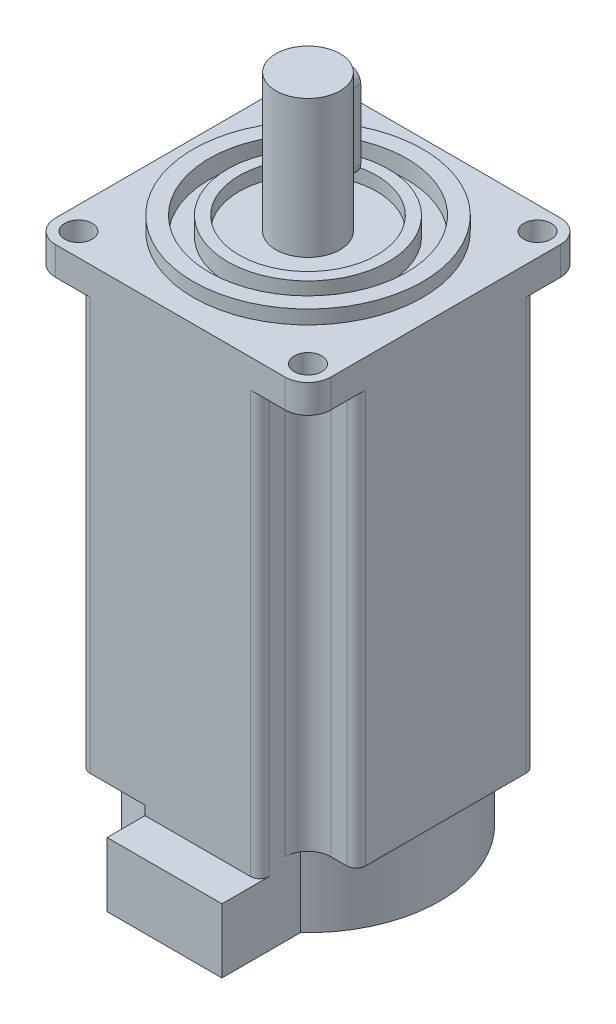
from build123d import *

# Parameters (mm, degrees)
SKETCH_2_W               = 60
SKETCH_2_H               = 60
EXTRUDE_1_DEPTH          = 96
SKETCH_3_W               = 10.5
SKETCH_3_H               = 10.5
CUT_EXTRUDE_1_DEPTH      = 97
PATTERN_CIRCULAR_1_COUNT = 4
SKETCH_4_W               = 60
SKETCH_4_H               = 60
EXTRUDE_2_DEPTH          = 6.2
SKETCH_5_R               = 25
EXTRUDE_3_DEPTH          = 3
SKETCH_8_R               = 21.5
SKETCH_8_R_2             = 17.5
CUT_EXTRUDE_3_DEPTH      = 4
SKETCH_9_R               = 15
CUT_EXTRUDE_4_DEPTH      = 3
SKETCH_10_R              = 7
EXTRUDE_5_DEPTH          = 30
FILLET_1_R               = 5
FILLET_2_R               = 2
FILLET_3_R               = 5
SKETCH_13_R              = 28.75
EXTRUDE_6_DEPTH          = 16
EXTRUDE_START            = 16
SKETCH_14_W              = 25
SKETCH_14_H              = 17.123890562
EXTRUDE_7_DEPTH          = 14
EXTRUDE_8_DEPTH          = 2
HOLE_WIZARD_6_0_6_1_D    = 6
CUT_EXTRUDE_5_DEPTH      = 3
EXTRUDE_9_DEPTH          = 5


with BuildPart() as part:
    # Sketch 2 → Extrude 1 (new body)
    with BuildSketch(Plane(origin=(0, 0, 0), x_dir=(1, 0, 0), z_dir=(0, 1, 0))):
        Rectangle(SKETCH_2_W, SKETCH_2_H)
    extrude(amount=-EXTRUDE_1_DEPTH)

    # Sketch 3 → Cut-Extrude 1 (cut, through all)
    with BuildSketch(Plane(origin=(0, 0, 0), x_dir=(1, 0, 0), z_dir=(0, 1, 0))):
        with Locations((-24.75, -24.75)):
            Rectangle(SKETCH_3_W, SKETCH_3_H)
    cut_extrude_1 = extrude(amount=-CUT_EXTRUDE_1_DEPTH, mode=Mode.SUBTRACT)

    # Pattern Circular 1: Cut-Extrude 1 ×4 about axis
    pattern_circular_1_axis = Axis((0, 0, 0), (0, 1, 0))
    for i in range(1, PATTERN_CIRCULAR_1_COUNT):
        add(cut_extrude_1.rotate(pattern_circular_1_axis, i * 360 / PATTERN_CIRCULAR_1_COUNT), mode=Mode.SUBTRACT)

    # Sketch 4 → Extrude 2 (add)
    with BuildSketch(Plane(origin=(0, 0, 0), x_dir=(1, 0, 0), z_dir=(0, 1, 0))):
        Rectangle(SKETCH_4_W, SKETCH_4_H)
    extrude(amount=-EXTRUDE_2_DEPTH)

    # Sketch 5 → Extrude 3 (add)
    with BuildSketch(Plane(origin=(0, 0, 0), x_dir=(1, 0, 0), z_dir=(0, 1, 0))):
        Circle(SKETCH_5_R)
    extrude(amount=EXTRUDE_3_DEPTH)

    # Sketch 8 → Cut-Extrude 3 (cut)
    with BuildSketch(Plane(origin=(0, 3, 0), x_dir=(1, 0, 0), z_dir=(0, 1, 0))):
        Circle(SKETCH_8_R)
        Circle(SKETCH_8_R_2, mode=Mode.SUBTRACT)
    extrude(amount=-CUT_EXTRUDE_3_DEPTH, mode=Mode.SUBTRACT)

    # Sketch 9 → Cut-Extrude 4 (cut)
    with BuildSketch(Plane(origin=(0, 3, 0), x_dir=(1, 0, 0), z_dir=(0, 1, 0))):
        Circle(SKETCH_9_R)
    extrude(amount=-CUT_EXTRUDE_4_DEPTH, mode=Mode.SUBTRACT)

    # Sketch 10 → Extrude 5 (add)
    with BuildSketch(Plane(origin=(0, 0, 0), x_dir=(1, 0, 0), z_dir=(0, 1, 0))):
        Circle(SKETCH_10_R)
    extrude(amount=EXTRUDE_5_DEPTH)

    # Fillet 1
    fillet_1_edges = [part.edges().sort_by_distance(p)[0] for p in [
        (-19.5, -51.1, 19.5),
        (-19.5, -51.1, -19.5),
        (19.5, -51.1, -19.5),
        (19.5, -51.1, 19.5),
    ]]
    fillet(fillet_1_edges, radius=FILLET_1_R)

    # Fillet 2
    fillet_2_edges = [part.edges().sort_by_distance(p)[0] for p in [
        (-30, -51.1, 19.5),
        (-19.5, -51.1, 30),
        (-19.5, -51.1, -30),
        (-30, -51.1, -19.5),
        (30, -51.1, -19.5),
        (19.5, -51.1, -30),
        (19.5, -51.1, 30),
        (30, -51.1, 19.5),
    ]]
    fillet(fillet_2_edges, radius=FILLET_2_R)

    # Fillet 3
    fillet_3_edges = [part.edges().sort_by_distance(p)[0] for p in [
        (30, -3.1, 30),
        (30, -3.1, -30),
        (-30, -3.1, -30),
        (-30, -3.1, 30),
    ]]
    fillet(fillet_3_edges, radius=FILLET_3_R)

    # Sketch 13 → Extrude 6 (add)
    with BuildSketch(Plane.XZ.offset(96)):
        Circle(SKETCH_13_R)
    extrude(amount=EXTRUDE_6_DEPTH)

    # Sketch 14 → Extrude 7 (add)
    with BuildSketch(Plane.XZ.offset(96).offset(EXTRUDE_START)):
        with Locations((7, 29.688054719)):
            Rectangle(SKETCH_14_W, SKETCH_14_H)
    extrude(amount=-EXTRUDE_7_DEPTH)

    # Sketch 15 → Extrude 8 (add)
    with BuildSketch(Plane(origin=(0, -98, 0), x_dir=(1, 0, 0), z_dir=(0, 1, 0))):
        with BuildLine():
            Line((-5.5, -30), (17.5, -30))
            ThreePointArc((17.5, -30), (18.914213562, -29.414213562), (19.5, -28))
            Line((19.5, -28), (19.5, -21.126109438))
            ThreePointArc((19.5, -21.126109438), (7.847121001, -27.658365678), (-5.5, -28.21900955))
            Line((-5.5, -28.21900955), (-5.5, -30))
        make_face()
    extrude(amount=EXTRUDE_8_DEPTH)

    # Hole Wizard 6.0 _6_ _1 (through all)
    with Locations(Plane(origin=(0, 0, 0), x_dir=(1, 0, 0), z_dir=(0, 1, 0))):
        with Locations((-25, 25), (25, 25), (25, -25), (-25, -25)):
            Hole(HOLE_WIZARD_6_0_6_1_D / 2)

    # Sketch 20 → Cut-Extrude 5 (cut)
    with BuildSketch(Plane.XY.offset(-7)):
        with BuildLine():
            Line((-2.5, 24.5), (-2.5, 9.5))
            ThreePointArc((-2.5, 9.5), (0, 7), (2.5, 9.5))
            Line((2.5, 9.5), (2.5, 24.5))
            ThreePointArc((2.5, 24.5), (0, 27), (-2.5, 24.5))
        make_face()
    extrude(amount=CUT_EXTRUDE_5_DEPTH, mode=Mode.SUBTRACT)

    # Sketch 21 → Extrude 9 (add)
    with BuildSketch(Plane(origin=(0, 0, -4), x_dir=(-1, 0, 0), z_dir=(0, 0, -1))):
        with BuildLine():
            Line((2.5, 9.5), (2.5, 24.5))
            ThreePointArc((2.5, 24.5), (0, 27), (-2.5, 24.5))
            Line((-2.5, 24.5), (-2.5, 9.5))
            ThreePointArc((-2.5, 9.5), (0, 7), (2.5, 9.5))
        make_face()
    extrude(amount=EXTRUDE_9_DEPTH)


solid = part.part
